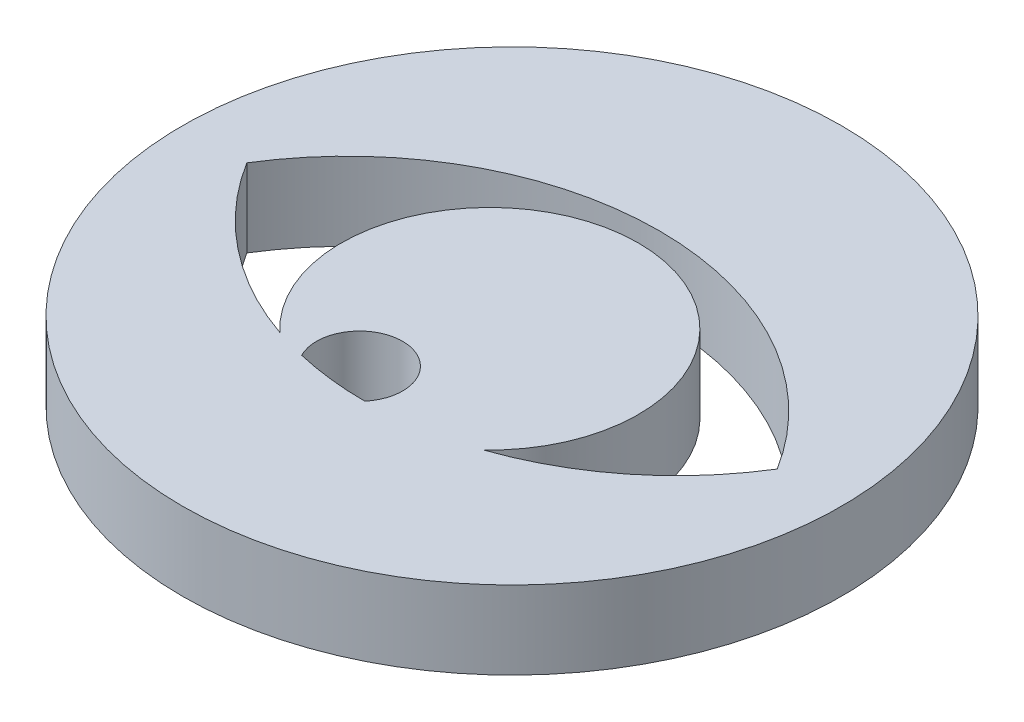
from build123d import *

# Parameters (mm, degrees)
SKETCH1_R           = 9.5
BOSS_EXTRUDE1_DEPTH = 2.25


with BuildPart() as part:
    # Sketch1 → Boss-Extrude1 (new body)
    with BuildSketch(Plane(origin=(0, 0, 0), x_dir=(1, 0, 0), z_dir=(0, 1, 0))):
        Circle(SKETCH1_R)
        with BuildLine():
            ThreePointArc((-2.050056302, -4.013405112), (-0.801449739, -2.21696931), (0.006631996, -4.249997556))
            ThreePointArc((0.006631996, -4.249997556), (-1.028537661, -4.191035191), (-2.050056302, -4.013405112))
        make_face(mode=Mode.SUBTRACT)
        with BuildLine():
            ThreePointArc((7.644442426, 0), (5.613326884, -2.284952828), (2.934499964, -3.758155497))
            ThreePointArc((2.934499964, -3.758155497), (0, 3.643549808), (-2.934499964, -3.758155497))
            ThreePointArc((-2.934499964, -3.758155497), (-5.613326884, -2.284952828), (-7.644442426, 0))
            ThreePointArc((-7.644442426, 0), (0, 4.25), (7.644442426, 0))
        make_face(mode=Mode.SUBTRACT)
    extrude(amount=BOSS_EXTRUDE1_DEPTH)


solid = part.part
